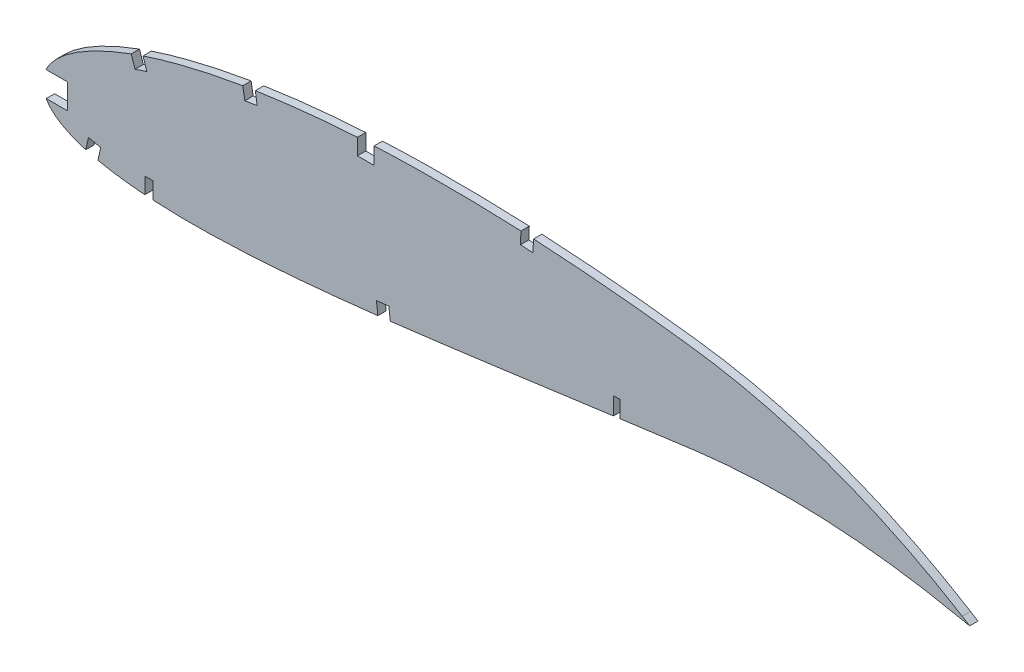
from build123d import *

# Parameters (mm, degrees)
BOSS_EXTRUDE1_DEPTH = 3.175
SKETCH2_W           = 3.175
SKETCH2_H           = 6.35
CUT_EXTRUDE1_DEPTH  = 7.62
SKETCH3_W           = 9.525
SKETCH3_H           = 9.525
CUT_EXTRUDE2_DEPTH  = 7.62


with BuildPart() as part:
    # Sketch1 → Boss-Extrude1 (new body)
    with BuildSketch(Plane.XY):
        with BuildLine():
            Line((349.874585492, 0.545463984), (352.707444634, -1.20455312))
            Line((352.707444634, -1.20455312), (349.438214508, -0.545463984))
            add(Edge.make_bspline(
                [(0, 0), (0.089846556, -0.42413566), (0.269952586, -1.274356233), (0.759277158, -2.498321594), (1.406385548, -3.674906843), (2.224859075, -4.800986693), (3.209255672, -5.876253384), (4.35740119, -6.901825315), (5.668169647, -7.877151063), (7.139845481, -8.801786749), (8.770290863, -9.676713909), (10.557673174, -10.501388578), (12.50036268, -11.27555304), (14.596242771, -11.998172434), (16.842751177, -12.670347293), (19.237752029, -13.290439574), (21.778521975, -13.85931597), (24.462617274, -14.375524359), (27.287113095, -14.839589189), (30.249075184, -15.251250745), (33.345463294, -15.610766498), (36.573239638, -15.91738207), (39.929211619, -16.171756957), (43.410034297, -16.374059922), (47.012328898, -16.524932447), (50.732644804, -16.623800998), (54.567338391, -16.67220693), (58.512944169, -16.670876946), (62.565602395, -16.61945532), (66.721851142, -16.520782763), (70.977702027, -16.374234263), (75.329312874, -16.181583233), (79.772758472, -15.944768433), (84.304053533, -15.664592692), (88.919210366, -15.34229772), (93.614221743, -14.980468162), (98.384822681, -14.580006537), (103.226852581, -14.143247039), (108.136024765, -13.672376169), (113.108097791, -13.168884156), (118.138682919, -12.635139453), (123.223299496, -12.072871655), (128.357622076, -11.485080459), (133.536960473, -10.872829323), (138.756934998, -10.239613946), (144.01263497, -9.586644137), (149.299665563, -8.916434941), (154.613271597, -8.232142042), (159.948478634, -7.533687389), (165.300799385, -6.826047184), (170.665072246, -6.10863863), (176.036627988, -5.385151352), (181.41049421, -4.657834169), (186.781436724, -3.926910937), (192.144734283, -3.195410776), (197.495411502, -2.465341803), (202.828227289, -1.736770722), (208.138356857, -1.01331884), (213.420453064, -0.29489769), (218.669645291, 0.417036129), (223.880903334, 1.120357576), (229.04931062, 1.814178993), (234.169535605, 2.498061398), (239.236426935, 3.172261632), (244.169031168, 3.816316009), (248.954459394, 4.464520656), (253.608837564, 4.995904796), (258.205262858, 5.449460294), (262.748509733, 5.821313195), (267.233122793, 6.116813381), (271.653963676, 6.33807231), (276.005763649, 6.488179014), (280.283025782, 6.571586638), (284.480407554, 6.590411838), (288.592179833, 6.550658117), (292.612994804, 6.455529945), (296.537240729, 6.309297175), (300.359442953, 6.116893422), (304.074172418, 5.88356379), (307.675852222, 5.61275005), (311.159463489, 5.31077448), (314.519631517, 4.982057677), (317.751196762, 4.630355277), (320.849443917, 4.263036843), (323.80941387, 3.882520808), (326.626654369, 3.495060385), (329.296630419, 3.104582143), (331.815113594, 2.716071228), (334.178146904, 2.333234142), (336.381913315, 1.961151961), (338.42296059, 1.603301248), (340.297747089, 1.263176546), (342.003671937, 0.945069457), (343.537365938, 0.650560023), (344.89677779, 0.384501923), (346.079379905, 0.148069019), (347.083438644, -0.055407417), (347.907200564, -0.225124582), (348.549414458, -0.358296262), (349.008811888, -0.455135342), (349.284895944, -0.512759554), (349.407563654, -0.538925841), (349.438214508, -0.545463984)],
                knots=[0, 0, 0, 0, 0.003638255, 0.007293231, 0.011028136, 0.014901081, 0.018963272, 0.023258475, 0.027820626, 0.032679082, 0.03785316, 0.043361875, 0.049214679, 0.055422346, 0.061988786, 0.068918036, 0.076211157, 0.083868392, 0.091887411, 0.100265912, 0.108999867, 0.118084529, 0.127514843, 0.13728527, 0.147387917, 0.15781648, 0.168563473, 0.179619128, 0.190977373, 0.202626974, 0.214560478, 0.226767249, 0.239236417, 0.251959004, 0.264923894, 0.278119702, 0.291536035, 0.305160279, 0.318980685, 0.332985499, 0.34716279, 0.361498602, 0.375980747, 0.390597192, 0.405332593, 0.420174823, 0.435109532, 0.450124275, 0.465203067, 0.480333154, 0.495500583, 0.510689775, 0.525887334, 0.541078314, 0.556247233, 0.571381784, 0.58646604, 0.601484516, 0.616424328, 0.631269422, 0.646006524, 0.660620684, 0.675098187, 0.689422858, 0.703581824, 0.716907563, 0.730009274, 0.742952128, 0.755725558, 0.768319951, 0.780724337, 0.792926529, 0.804916041, 0.816679084, 0.828203524, 0.8394749, 0.850481359, 0.861207696, 0.871639325, 0.881763414, 0.891563605, 0.901027364, 0.910138977, 0.918883976, 0.927249278, 0.935221103, 0.942784738, 0.949928187, 0.956638464, 0.962904203, 0.968712287, 0.974054484, 0.978918432, 0.983297218, 0.987180246, 0.990560674, 0.993433357, 0.995790625, 0.997629587, 0.998945816, 0.999736592, 1, 1, 1, 1], degree=3))
            add(Edge.make_bspline(
                [(349.874585492, 0.545463984), (349.84778287, 0.562021478), (349.740676385, 0.628187203), (349.499345966, 0.776216), (349.097480631, 1.022765407), (348.534904305, 1.366122907), (347.812053852, 1.805376859), (346.928565422, 2.337451142), (345.884990684, 2.960617427), (344.681582261, 3.67192829), (343.318463463, 4.468053151), (341.796153348, 5.345766934), (340.114784198, 6.300100143), (338.275007553, 7.327153668), (336.277454595, 8.422042859), (334.122503071, 9.57982248), (331.810924623, 10.794603269), (329.343606792, 12.061160753), (326.720999264, 13.372500177), (323.94433864, 14.723164515), (321.014549884, 16.106419105), (317.932632954, 17.514883916), (314.700358537, 18.942817663), (311.318620248, 20.381342636), (307.789345254, 21.824226627), (304.114035971, 23.263257402), (300.294868588, 24.691881816), (296.333316521, 26.10084431), (292.232341223, 27.48398811), (287.993932043, 28.832327649), (283.621119941, 30.138540114), (279.116445698, 31.394156819), (274.483664423, 32.592738274), (269.725714187, 33.725555633), (264.846627655, 34.785026629), (259.850283242, 35.764772317), (254.74087123, 36.65501141), (249.532550289, 37.455049817), (244.309121072, 38.12054629), (239.096438625, 38.773245817), (233.891519128, 39.386397341), (228.62298462, 39.973574713), (223.295903739, 40.531472038), (217.915560522, 41.058344765), (212.48740178, 41.551918975), (207.017068371, 42.010747226), (201.50985363, 42.432229596), (195.971564619, 42.815716764), (190.407676675, 43.157837372), (184.824116001, 43.458334576), (179.226550658, 43.715112597), (173.620805826, 43.926402175), (168.012834012, 44.090927801), (162.408456479, 44.20711327), (156.813741345, 44.274228097), (151.234507983, 44.290438421), (145.676821678, 44.255454251), (140.146502239, 44.168074381), (134.649621139, 44.027102616), (129.192006124, 43.832275845), (123.779558755, 43.583678577), (118.418205112, 43.279228984), (113.113761309, 42.92086723), (107.872134275, 42.507087935), (102.699083074, 42.03778105), (97.60002911, 41.514902823), (92.580649376, 40.937031104), (87.646323129, 40.305810102), (82.802447525, 39.62247743), (78.054457529, 38.886660836), (73.407439292, 38.100485727), (68.866408275, 37.264756455), (64.436168878, 36.381923118), (60.121544455, 35.452216047), (55.927102264, 34.478424084), (51.857201424, 33.462243838), (47.916216984, 32.405535604), (44.108143965, 31.310835019), (40.436833156, 30.180625631), (36.906564432, 29.016149332), (33.520005897, 27.821821268), (30.281317597, 26.598489281), (27.192980463, 25.349922105), (24.25861379, 24.07782455), (21.480409666, 22.78607462), (18.861512382, 21.476142937), (16.403788439, 20.151699481), (14.109705191, 18.814775138), (11.981470954, 17.46785311), (10.019980202, 16.114349944), (8.227937298, 14.75511519), (6.605957835, 13.393583581), (5.155068251, 12.031828375), (3.87734245, 10.670787626), (2.772734444, 9.312858131), (1.842691864, 7.959115327), (1.087376063, 6.610840176), (0.508495443, 5.269012088), (0.105475974, 3.934385674), (-0.11513418, 2.608930803), (-0.170045383, 1.291584884), (-0.056597102, 0.42988501), (0, 0)],
                knots=[0, 0, 0, 0, 0.00025409, 0.001015373, 0.002283359, 0.004056577, 0.006330981, 0.009105274, 0.012374489, 0.016134023, 0.02037966, 0.025105976, 0.030306237, 0.035972206, 0.042099522, 0.048678063, 0.055701664, 0.063160184, 0.071045824, 0.079349826, 0.08806291, 0.097175756, 0.106678112, 0.116561573, 0.126814275, 0.1374283, 0.148393617, 0.15969976, 0.171338125, 0.183297699, 0.195569604, 0.208143556, 0.221011593, 0.234161831, 0.24758745, 0.261276823, 0.27522271, 0.289414144, 0.3037712, 0.317689226, 0.331784111, 0.346039676, 0.360443869, 0.37498272, 0.389640454, 0.404403316, 0.419256601, 0.434186749, 0.449177265, 0.464214782, 0.479284009, 0.49436974, 0.509457833, 0.524532346, 0.53957932, 0.554582984, 0.569529546, 0.584403417, 0.599190992, 0.613876838, 0.628447475, 0.642888675, 0.657186054, 0.671325546, 0.685294014, 0.699078147, 0.712665095, 0.726042645, 0.739197713, 0.752117586, 0.764792042, 0.777208152, 0.789355685, 0.80122396, 0.812803685, 0.824082909, 0.835054602, 0.845709571, 0.856037853, 0.866033834, 0.875688843, 0.884997719, 0.893953426, 0.902552897, 0.910789386, 0.918660734, 0.926166253, 0.933302626, 0.94007122, 0.94647478, 0.952517526, 0.958204819, 0.963546652, 0.9685566, 0.973249913, 0.977651041, 0.981787043, 0.985694226, 0.989415109, 0.993001157, 0.996508416, 1, 1, 1, 1], degree=3))
        make_face()
    extrude(amount=BOSS_EXTRUDE1_DEPTH)

    # Sketch2 → Cut-Extrude1 (cut)
    with BuildSketch(Plane(origin=(0, 0, 0), x_dir=(-1, 0, 0), z_dir=(0, 0, -1))):
        Polygon((-219.606554447, 6.914833959), (-217.066554447, 6.914833959), (-217.066554447, 0.564687977), (-217.066554447, -0.789930881), (-219.606554447, -0.112621452), (-219.606554447, 0.564687977), align=None)
        Polygon((-125.944054447, 43.593406611), (-125.944054447, 37.241023539), (-119.594054447, 37.241023539), (-119.594054447, 43.593406611), (-119.594054447, 44.802397228), (-125.944054447, 46.495670801), align=None)
        with Locations((-40.219054447, -13.103372293)):
            Rectangle(SKETCH2_W, SKETCH2_H)
    extrude(amount=-CUT_EXTRUDE1_DEPTH, mode=Mode.SUBTRACT)

    # Sketch3 → Cut-Extrude2 (cut)
    with BuildSketch(Plane.XY.offset(3.175)):
        with Locations((4.355371843, 1.645821512)):
            Rectangle(SKETCH3_W, SKETCH3_H)
        Polygon((16.171457382, -12.545249924), (15.705940357, -14.401888263), (20.327485108, -15.560653391), (20.793002133, -13.704015053), (21.83918578, -8.906732132), (17.186142344, -7.892061471), align=None)
        with BuildLine():
            Line((39.42133882, 24.947712418), (37.914907365, 29.465538685))
            add(Edge.make_bspline(
                [(37.914907365, 29.465538685), (37.503075491, 29.328229708), (35.998678939, 28.820692893), (34.501078585, 28.29321423), (33.417210722, 27.898290266)],
                knots=[0, 0, 0, 0, 0.273427544, 1, 1, 1, 1], degree=3))
            Line((33.417210722, 27.898290266), (34.903383719, 23.441235893))
            Line((34.903383719, 23.441235893), (39.42133882, 24.947712418))
        make_face()
        Polygon((127.368342473, -11.617537485), (127.634396869, -13.885543313), (132.379617898, -13.328892664), (132.113563501, -11.060886836), (131.550455412, -6.324317398), (126.821258672, -6.886548949), align=None)
        with BuildLine():
            Line((81.423558796, 34.68031468), (80.699379538, 39.387502266))
            add(Edge.make_bspline(
                [(80.699379538, 39.387502266), (79.775759227, 39.245393844), (78.185850824, 38.994290384), (76.597742692, 38.732069255), (75.931982079, 38.620080212)],
                knots=[0, 0, 0, 0, 0.580571145, 1, 1, 1, 1], degree=3))
            Line((75.931982079, 38.620080212), (76.716438453, 33.956145329))
            Line((76.716438453, 33.956145329), (81.423558796, 34.68031468))
        make_face()
        with BuildLine():
            Line((186.403364239, 38.691487846), (186.65218162, 43.447445327))
            ThreePointArc((186.65218162, 43.447445327), (184.257847491, 43.568655733), (181.863115977, 43.681743585))
            Line((181.863115977, 43.681743585), (181.647368287, 38.940234557))
            Line((181.647368287, 38.940234557), (186.403364239, 38.691487846))
        make_face()
    extrude(amount=-CUT_EXTRUDE2_DEPTH, mode=Mode.SUBTRACT)


solid = part.part
